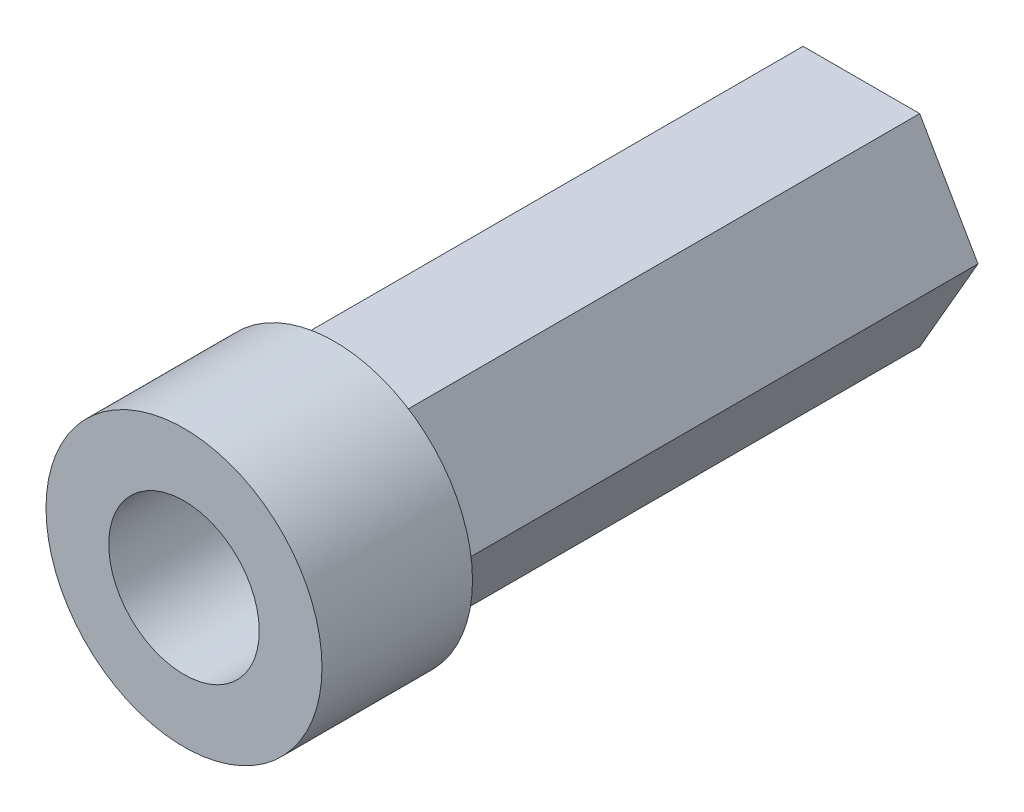
from build123d import *

# Parameters (mm, degrees)
SKETCH_1_R      = 5.5
SKETCH_1_R_2    = 3
EXTRUDE_1_DEPTH = 6
EXTRUDE_START   = -21
SKETCH_1_3_R    = 3
EXTRUDE_2_DEPTH = 21


with BuildPart() as part:
    # 草图1 → 凸台-拉伸1 (new body)
    with BuildSketch(Plane.XY):
        Circle(SKETCH_1_R)
        Circle(SKETCH_1_R_2, mode=Mode.SUBTRACT)
    extrude(amount=EXTRUDE_1_DEPTH)

    # 草图1<3> → 凸台-拉伸2 (add)
    with BuildSketch(Plane.XY.offset(EXTRUDE_START)):
        Polygon((2.323834833, 4.025), (-2.323834833, 4.025), (-4.647669667, 0), (-2.323834833, -4.025), (2.323834833, -4.025), (4.647669667, 0), align=None)
        Circle(SKETCH_1_3_R, mode=Mode.SUBTRACT)
    extrude(amount=EXTRUDE_2_DEPTH)


solid = part.part
